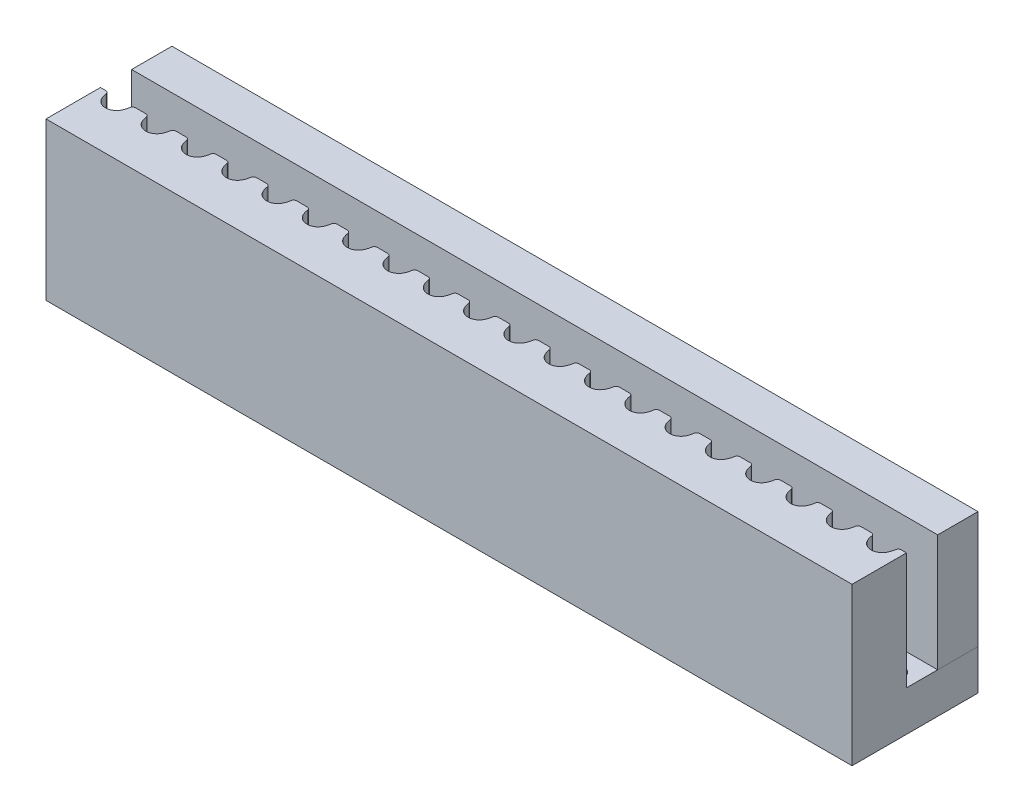
from build123d import *

# Parameters (mm, degrees)
BOSS_EXTRUDE1_DEPTH   = 5.8
SKETCH1_W             = 40
SKETCH1_H             = 2
BOSS_EXTRUDE1_2_DEPTH = 5.8
SKETCH2_W             = 40
SKETCH2_H             = 6.25
SKETCH2_R             = 0.5
BOSS_EXTRUDE2_DEPTH   = 2


with BuildPart() as part:
    # Sketch1 → Boss-Extrude1 (new body)
    with BuildSketch(Plane(origin=(0, 0, 0), x_dir=(1, 0, 0), z_dir=(0, 1, 0))):
        with BuildLine():
            Line((-19.740175425, 0.32), (-20, 0.32))
            Line((-20, 0.32), (-20, -2.38))
            Line((-20, -2.38), (20, -2.38))
            Line((20, -2.38), (20, 0.32))
            Line((20, 0.32), (19.740175425, 0.32))
            ThreePointArc((19.740175425, 0.32), (19.641268354, 0.282771412), (19.591456891, 0.189565217))
            ThreePointArc((19.591456891, 0.189565217), (19.557611714, 0.031937846), (19.498876404, -0.118202247))
            ThreePointArc((19.498876404, -0.118202247), (19, -0.43), (18.501123596, -0.118202247))
            ThreePointArc((18.501123596, -0.118202247), (18.442388286, 0.031937846), (18.408543109, 0.189565217))
            ThreePointArc((18.408543109, 0.189565217), (18.358731646, 0.282771412), (18.259824575, 0.32))
            Line((18.259824575, 0.32), (17.740175425, 0.32))
            ThreePointArc((17.740175425, 0.32), (17.641268354, 0.282771412), (17.591456891, 0.189565217))
            ThreePointArc((17.591456891, 0.189565217), (17.557611714, 0.031937846), (17.498876404, -0.118202247))
            ThreePointArc((17.498876404, -0.118202247), (17, -0.43), (16.501123596, -0.118202247))
            ThreePointArc((16.501123596, -0.118202247), (16.442388286, 0.031937846), (16.408543109, 0.189565217))
            ThreePointArc((16.408543109, 0.189565217), (16.358731646, 0.282771412), (16.259824575, 0.32))
            Line((16.259824575, 0.32), (15.740175425, 0.32))
            ThreePointArc((15.740175425, 0.32), (15.641268354, 0.282771412), (15.591456891, 0.189565217))
            ThreePointArc((15.591456891, 0.189565217), (15.557611714, 0.031937846), (15.498876404, -0.118202247))
            ThreePointArc((15.498876404, -0.118202247), (15, -0.43), (14.501123596, -0.118202247))
            ThreePointArc((14.501123596, -0.118202247), (14.442388286, 0.031937846), (14.408543109, 0.189565217))
            ThreePointArc((14.408543109, 0.189565217), (14.358731646, 0.282771412), (14.259824575, 0.32))
            Line((14.259824575, 0.32), (13.740175425, 0.32))
            ThreePointArc((13.740175425, 0.32), (13.641268354, 0.282771412), (13.591456891, 0.189565217))
            ThreePointArc((13.591456891, 0.189565217), (13.557611714, 0.031937846), (13.498876404, -0.118202247))
            ThreePointArc((13.498876404, -0.118202247), (13, -0.43), (12.501123596, -0.118202247))
            ThreePointArc((12.501123596, -0.118202247), (12.442388286, 0.031937846), (12.408543109, 0.189565217))
            ThreePointArc((12.408543109, 0.189565217), (12.358731646, 0.282771412), (12.259824575, 0.32))
            Line((12.259824575, 0.32), (11.740175425, 0.32))
            ThreePointArc((11.740175425, 0.32), (11.641268354, 0.282771412), (11.591456891, 0.189565217))
            ThreePointArc((11.591456891, 0.189565217), (11.557611714, 0.031937846), (11.498876404, -0.118202247))
            ThreePointArc((11.498876404, -0.118202247), (11, -0.43), (10.501123596, -0.118202247))
            ThreePointArc((10.501123596, -0.118202247), (10.442388286, 0.031937846), (10.408543109, 0.189565217))
            ThreePointArc((10.408543109, 0.189565217), (10.358731646, 0.282771412), (10.259824575, 0.32))
            Line((10.259824575, 0.32), (9.740175425, 0.32))
            ThreePointArc((9.740175425, 0.32), (9.641268354, 0.282771412), (9.591456891, 0.189565217))
            ThreePointArc((9.591456891, 0.189565217), (9.557611714, 0.031937846), (9.498876404, -0.118202247))
            ThreePointArc((9.498876404, -0.118202247), (9, -0.43), (8.501123596, -0.118202247))
            ThreePointArc((8.501123596, -0.118202247), (8.442388286, 0.031937846), (8.408543109, 0.189565217))
            ThreePointArc((8.408543109, 0.189565217), (8.358731646, 0.282771412), (8.259824575, 0.32))
            Line((8.259824575, 0.32), (7.740175425, 0.32))
            ThreePointArc((7.740175425, 0.32), (7.641268354, 0.282771412), (7.591456891, 0.189565217))
            ThreePointArc((7.591456891, 0.189565217), (7.557611714, 0.031937846), (7.498876404, -0.118202247))
            ThreePointArc((7.498876404, -0.118202247), (7, -0.43), (6.501123596, -0.118202247))
            ThreePointArc((6.501123596, -0.118202247), (6.442388286, 0.031937846), (6.408543109, 0.189565217))
            ThreePointArc((6.408543109, 0.189565217), (6.358731646, 0.282771412), (6.259824575, 0.32))
            Line((6.259824575, 0.32), (5.740175425, 0.32))
            ThreePointArc((5.740175425, 0.32), (5.641268354, 0.282771412), (5.591456891, 0.189565217))
            ThreePointArc((5.591456891, 0.189565217), (5.557611714, 0.031937846), (5.498876404, -0.118202247))
            ThreePointArc((5.498876404, -0.118202247), (5, -0.43), (4.501123596, -0.118202247))
            ThreePointArc((4.501123596, -0.118202247), (4.442388286, 0.031937846), (4.408543109, 0.189565217))
            ThreePointArc((4.408543109, 0.189565217), (4.358731646, 0.282771412), (4.259824575, 0.32))
            Line((4.259824575, 0.32), (3.740175425, 0.32))
            ThreePointArc((3.740175425, 0.32), (3.641268354, 0.282771412), (3.591456891, 0.189565217))
            ThreePointArc((3.591456891, 0.189565217), (3.557611714, 0.031937846), (3.498876404, -0.118202247))
            ThreePointArc((3.498876404, -0.118202247), (3, -0.43), (2.501123596, -0.118202247))
            ThreePointArc((2.501123596, -0.118202247), (2.442388286, 0.031937846), (2.408543109, 0.189565217))
            ThreePointArc((2.408543109, 0.189565217), (2.358731646, 0.282771412), (2.259824575, 0.32))
            Line((2.259824575, 0.32), (1.740175425, 0.32))
            ThreePointArc((1.740175425, 0.32), (1.641268354, 0.282771412), (1.591456891, 0.189565217))
            ThreePointArc((1.591456891, 0.189565217), (1.557611714, 0.031937846), (1.498876404, -0.118202247))
            ThreePointArc((1.498876404, -0.118202247), (1, -0.43), (0.501123596, -0.118202247))
            ThreePointArc((0.501123596, -0.118202247), (0.442388286, 0.031937846), (0.408543109, 0.189565217))
            ThreePointArc((0.408543109, 0.189565217), (0.358731646, 0.282771412), (0.259824575, 0.32))
            Line((0.259824575, 0.32), (-0.259824575, 0.32))
            ThreePointArc((-0.259824575, 0.32), (-0.358731646, 0.282771412), (-0.408543109, 0.189565217))
            ThreePointArc((-0.408543109, 0.189565217), (-0.442388286, 0.031937846), (-0.501123596, -0.118202247))
            ThreePointArc((-0.501123596, -0.118202247), (-1, -0.43), (-1.498876404, -0.118202247))
            ThreePointArc((-1.498876404, -0.118202247), (-1.557611714, 0.031937846), (-1.591456891, 0.189565217))
            ThreePointArc((-1.591456891, 0.189565217), (-1.641268354, 0.282771412), (-1.740175425, 0.32))
            Line((-1.740175425, 0.32), (-2.259824575, 0.32))
            ThreePointArc((-2.259824575, 0.32), (-2.358731646, 0.282771412), (-2.408543109, 0.189565217))
            ThreePointArc((-2.408543109, 0.189565217), (-2.442388286, 0.031937846), (-2.501123596, -0.118202247))
            ThreePointArc((-2.501123596, -0.118202247), (-3, -0.43), (-3.498876404, -0.118202247))
            ThreePointArc((-3.498876404, -0.118202247), (-3.557611714, 0.031937846), (-3.591456891, 0.189565217))
            ThreePointArc((-3.591456891, 0.189565217), (-3.641268354, 0.282771412), (-3.740175425, 0.32))
            Line((-3.740175425, 0.32), (-4.259824575, 0.32))
            ThreePointArc((-4.259824575, 0.32), (-4.358731646, 0.282771412), (-4.408543109, 0.189565217))
            ThreePointArc((-4.408543109, 0.189565217), (-4.442388286, 0.031937846), (-4.501123596, -0.118202247))
            ThreePointArc((-4.501123596, -0.118202247), (-5, -0.43), (-5.498876404, -0.118202247))
            ThreePointArc((-5.498876404, -0.118202247), (-5.557611714, 0.031937846), (-5.591456891, 0.189565217))
            ThreePointArc((-5.591456891, 0.189565217), (-5.641268354, 0.282771412), (-5.740175425, 0.32))
            Line((-5.740175425, 0.32), (-6.259824575, 0.32))
            ThreePointArc((-6.259824575, 0.32), (-6.358731646, 0.282771412), (-6.408543109, 0.189565217))
            ThreePointArc((-6.408543109, 0.189565217), (-6.442388286, 0.031937846), (-6.501123596, -0.118202247))
            ThreePointArc((-6.501123596, -0.118202247), (-7, -0.43), (-7.498876404, -0.118202247))
            ThreePointArc((-7.498876404, -0.118202247), (-7.557611714, 0.031937846), (-7.591456891, 0.189565217))
            ThreePointArc((-7.591456891, 0.189565217), (-7.641268354, 0.282771412), (-7.740175425, 0.32))
            Line((-7.740175425, 0.32), (-8.259824575, 0.32))
            ThreePointArc((-8.259824575, 0.32), (-8.358731646, 0.282771412), (-8.408543109, 0.189565217))
            ThreePointArc((-8.408543109, 0.189565217), (-8.442388286, 0.031937846), (-8.501123596, -0.118202247))
            ThreePointArc((-8.501123596, -0.118202247), (-9, -0.43), (-9.498876404, -0.118202247))
            ThreePointArc((-9.498876404, -0.118202247), (-9.557611714, 0.031937846), (-9.591456891, 0.189565217))
            ThreePointArc((-9.591456891, 0.189565217), (-9.641268354, 0.282771412), (-9.740175425, 0.32))
            Line((-9.740175425, 0.32), (-10.259824575, 0.32))
            ThreePointArc((-10.259824575, 0.32), (-10.358731646, 0.282771412), (-10.408543109, 0.189565217))
            ThreePointArc((-10.408543109, 0.189565217), (-10.442388286, 0.031937846), (-10.501123596, -0.118202247))
            ThreePointArc((-10.501123596, -0.118202247), (-11, -0.43), (-11.498876404, -0.118202247))
            ThreePointArc((-11.498876404, -0.118202247), (-11.557611714, 0.031937846), (-11.591456891, 0.189565217))
            ThreePointArc((-11.591456891, 0.189565217), (-11.641268354, 0.282771412), (-11.740175425, 0.32))
            Line((-11.740175425, 0.32), (-12.259824575, 0.32))
            ThreePointArc((-12.259824575, 0.32), (-12.358731646, 0.282771412), (-12.408543109, 0.189565217))
            ThreePointArc((-12.408543109, 0.189565217), (-12.442388286, 0.031937846), (-12.501123596, -0.118202247))
            ThreePointArc((-12.501123596, -0.118202247), (-13, -0.43), (-13.498876404, -0.118202247))
            ThreePointArc((-13.498876404, -0.118202247), (-13.557611714, 0.031937846), (-13.591456891, 0.189565217))
            ThreePointArc((-13.591456891, 0.189565217), (-13.641268354, 0.282771412), (-13.740175425, 0.32))
            Line((-13.740175425, 0.32), (-14.259824575, 0.32))
            ThreePointArc((-14.259824575, 0.32), (-14.358731646, 0.282771412), (-14.408543109, 0.189565217))
            ThreePointArc((-14.408543109, 0.189565217), (-14.442388286, 0.031937846), (-14.501123596, -0.118202247))
            ThreePointArc((-14.501123596, -0.118202247), (-15, -0.43), (-15.498876404, -0.118202247))
            ThreePointArc((-15.498876404, -0.118202247), (-15.557611714, 0.031937846), (-15.591456891, 0.189565217))
            ThreePointArc((-15.591456891, 0.189565217), (-15.641268354, 0.282771412), (-15.740175425, 0.32))
            Line((-15.740175425, 0.32), (-16.259824575, 0.32))
            ThreePointArc((-16.259824575, 0.32), (-16.358731646, 0.282771412), (-16.408543109, 0.189565217))
            ThreePointArc((-16.408543109, 0.189565217), (-16.442388286, 0.031937846), (-16.501123596, -0.118202247))
            ThreePointArc((-16.501123596, -0.118202247), (-17, -0.43), (-17.498876404, -0.118202247))
            ThreePointArc((-17.498876404, -0.118202247), (-17.557611714, 0.031937846), (-17.591456891, 0.189565217))
            ThreePointArc((-17.591456891, 0.189565217), (-17.641268354, 0.282771412), (-17.740175425, 0.32))
            Line((-17.740175425, 0.32), (-18.259824575, 0.32))
            ThreePointArc((-18.259824575, 0.32), (-18.358731646, 0.282771412), (-18.408543109, 0.189565217))
            ThreePointArc((-18.408543109, 0.189565217), (-18.442388286, 0.031937846), (-18.501123596, -0.118202247))
            ThreePointArc((-18.501123596, -0.118202247), (-19, -0.43), (-19.498876404, -0.118202247))
            ThreePointArc((-19.498876404, -0.118202247), (-19.557611714, 0.031937846), (-19.591456891, 0.189565217))
            ThreePointArc((-19.591456891, 0.189565217), (-19.641268354, 0.282771412), (-19.740175425, 0.32))
        make_face()
    extrude(amount=BOSS_EXTRUDE1_DEPTH)

    # Sketch2 → Boss-Extrude2 (add)
    with BuildSketch(Plane.XZ):
        with Locations((0, -0.745)):
            Rectangle(SKETCH2_W, SKETCH2_H)
        with Locations((-19, -0.67)):
            Circle(SKETCH2_R, mode=Mode.SUBTRACT)
        with Locations((-17, -0.67)):
            Circle(SKETCH2_R, mode=Mode.SUBTRACT)
        with Locations((-15, -0.67)):
            Circle(SKETCH2_R, mode=Mode.SUBTRACT)
        with Locations((-13, -0.67)):
            Circle(SKETCH2_R, mode=Mode.SUBTRACT)
        with Locations((-11, -0.67)):
            Circle(SKETCH2_R, mode=Mode.SUBTRACT)
        with Locations((-9, -0.67)):
            Circle(SKETCH2_R, mode=Mode.SUBTRACT)
        with Locations((-7, -0.67)):
            Circle(SKETCH2_R, mode=Mode.SUBTRACT)
        with Locations((-5, -0.67)):
            Circle(SKETCH2_R, mode=Mode.SUBTRACT)
        with Locations((-3, -0.67)):
            Circle(SKETCH2_R, mode=Mode.SUBTRACT)
        with Locations((-1, -0.67)):
            Circle(SKETCH2_R, mode=Mode.SUBTRACT)
        with Locations((1, -0.67)):
            Circle(SKETCH2_R, mode=Mode.SUBTRACT)
        with Locations((3, -0.67)):
            Circle(SKETCH2_R, mode=Mode.SUBTRACT)
        with Locations((5, -0.67)):
            Circle(SKETCH2_R, mode=Mode.SUBTRACT)
        with Locations((7, -0.67)):
            Circle(SKETCH2_R, mode=Mode.SUBTRACT)
        with Locations((9, -0.67)):
            Circle(SKETCH2_R, mode=Mode.SUBTRACT)
        with Locations((11, -0.67)):
            Circle(SKETCH2_R, mode=Mode.SUBTRACT)
        with Locations((13, -0.67)):
            Circle(SKETCH2_R, mode=Mode.SUBTRACT)
        with Locations((15, -0.67)):
            Circle(SKETCH2_R, mode=Mode.SUBTRACT)
        with Locations((17, -0.67)):
            Circle(SKETCH2_R, mode=Mode.SUBTRACT)
        with Locations((19, -0.67)):
            Circle(SKETCH2_R, mode=Mode.SUBTRACT)
    extrude(amount=BOSS_EXTRUDE2_DEPTH)


with BuildPart() as body_2:
    # Sketch1 → Boss-Extrude1 2 (new body)
    with BuildSketch(Plane(origin=(0, 0, 0), x_dir=(1, 0, 0), z_dir=(0, 1, 0))):
        with Locations((0, 2.87)):
            Rectangle(SKETCH1_W, SKETCH1_H)
    extrude(amount=BOSS_EXTRUDE1_2_DEPTH)


solid = Compound([part.part, body_2.part])
